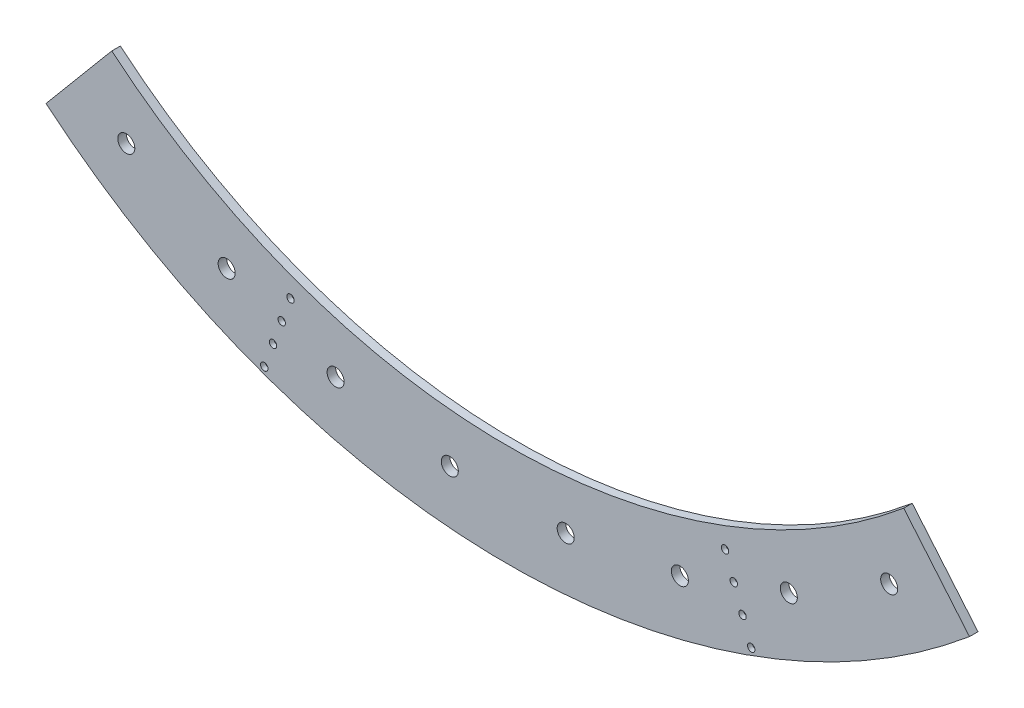
from build123d import *

# Parameters (mm, degrees)
BOSS_EXTRUDE1_DEPTH                              = 12.7
F_1_1_DIAMETER_HOLE1_D                           = 25.4
CBORE_FOR_1_4_SOCKET_HEAD_CAP_SCREW1_D           = 6.5278
CBORE_FOR_1_4_SOCKET_HEAD_CAP_SCREW1_CBORE_D     = 11.1125
CBORE_FOR_1_4_SOCKET_HEAD_CAP_SCREW1_CBORE_DEPTH = 7.112


with BuildPart() as part:
    # Sketch → Boss-Extrude1 (new body)
    with BuildSketch(Plane.XY):
        with BuildLine():
            Line((589.805840958, -702.903229895), (687.766672674, -819.648403026))
            ThreePointArc((687.766672674, -819.648403026), (0, -1069.975), (-687.766672674, -819.648403026))
            Line((-687.766672674, -819.648403026), (-589.805840958, -702.903229895))
            ThreePointArc((-589.805840958, -702.903229895), (0, -917.575), (589.805840958, -702.903229895))
        make_face()
    extrude(amount=BOSS_EXTRUDE1_DEPTH)

    # 1 (1) Diameter Hole1 (through all)
    with Locations(Plane.XY.offset(12.7)):
        with Locations((568.184817849, -811.452015073), (-418.64565008, -897.788493839), (418.64565008, -897.788493839), (-568.184817849, -811.452015073), (256.386146079, -956.846123522), (86.336478766, -986.83046793), (-86.336478766, -986.83046793), (-256.386146079, -956.846123522)):
            Hole(F_1_1_DIAMETER_HOLE1_D / 2)

    # CBORE for 1/4 Socket Head Cap Screw1 (through all)
    with Locations(Plane(origin=(11.711156934, 16.229076172, 12.7), x_dir=(-1, 0, 0), z_dir=(0, 0, 1))):
        with Locations((-350.984104056, 1012.726115884), (-324.922169134, 941.121538181), (-311.891201673, 905.319249329), (-337.953136595, 976.923827032), (335.313515542, 905.319249329), (348.344483002, 941.121538181), (361.375450463, 976.923827032), (374.406417924, 1012.726115884)):
            CounterBoreHole(CBORE_FOR_1_4_SOCKET_HEAD_CAP_SCREW1_D / 2, CBORE_FOR_1_4_SOCKET_HEAD_CAP_SCREW1_CBORE_D / 2, CBORE_FOR_1_4_SOCKET_HEAD_CAP_SCREW1_CBORE_DEPTH)


solid = part.part
